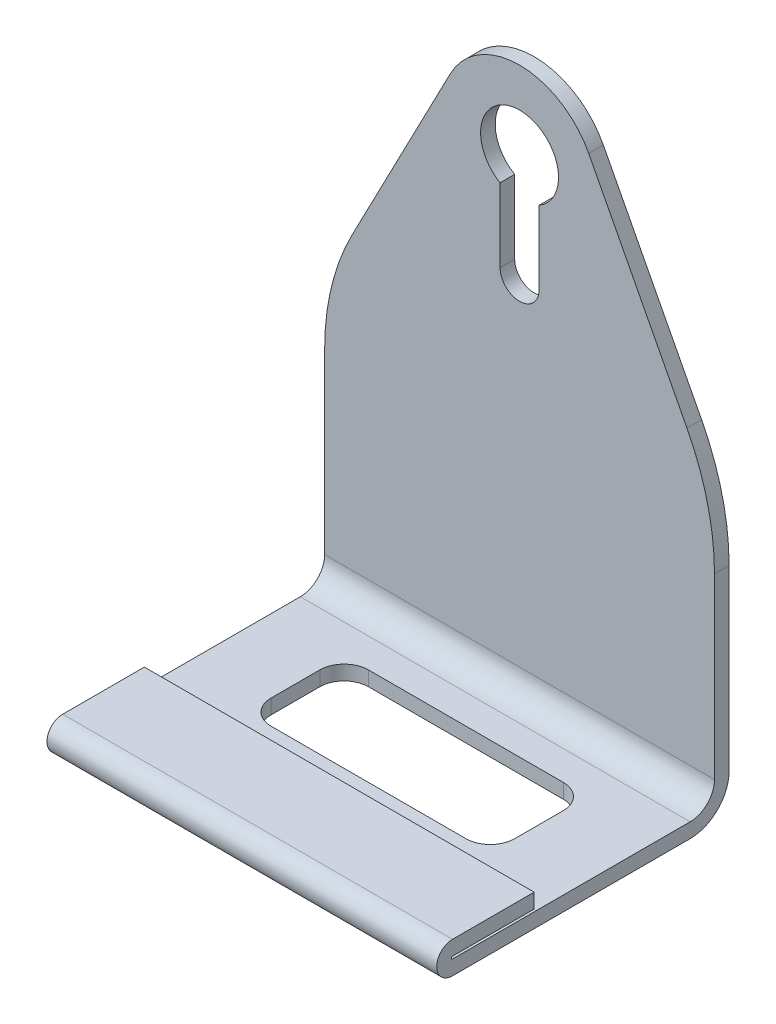
from build123d import *

# Parameters (mm, degrees)
BOSS_EXTRUDE1_DEPTH     = 40
CUT_EXTRUDE2_DEPTH      = 58
CUT_EXTRUDE2_DEPTH_BACK = 4
FILLET2_R               = 50
SKETCH4_R               = 8
CUT_EXTRUDE4_DEPTH      = 58
CUT_EXTRUDE4_DEPTH_BACK = 4
CUT_EXTRUDE5_DEPTH      = 113
CUT_EXTRUDE5_DEPTH_BACK = 4


with BuildPart() as part:
    # Sketch1 → Boss-Extrude1 (new body, symmetric)
    with BuildSketch(Plane.YZ):
        with BuildLine():
            Line((8, 0), (115, 0))
            Line((115, 0), (115, 3))
            Line((115, 3), (8, 3))
            ThreePointArc((8, 3), (4.464466094, 4.464466094), (3, 8))
            Line((3, 8), (3, 56.75))
            ThreePointArc((3, 56.75), (3.25, 57), (3.5, 56.75))
            Line((3.5, 56.75), (3.5, 40))
            Line((3.5, 40), (6.5, 40))
            Line((6.5, 40), (6.5, 56.75))
            ThreePointArc((6.5, 56.75), (3.25, 60), (0, 56.75))
            Line((0, 56.75), (0, 8))
            ThreePointArc((0, 8), (2.343145751, 2.343145751), (8, 0))
        make_face()
    extrude(amount=BOSS_EXTRUDE1_DEPTH, both=True)

    # Sketch2 → Cut-Extrude2 (cut, two sides)
    with BuildSketch(Plane.XY.offset(3)) as cut_extrude2_sk:
        with BuildLine():
            Line((-135.973206715, -127.551210724), (-40, 56.811604044))
            Line((-40, 56.811604044), (-14.192173331, 106.387977812))
            ThreePointArc((-14.192173331, 106.387977812), (0, 115), (14.192173331, 106.387977812))
            Line((14.192173331, 106.387977812), (40, 56.811604044))
            Line((40, 56.811604044), (135.973206715, -127.551210724))
            Line((135.973206715, -127.551210724), (135.973206715, 288.143407362))
            Line((135.973206715, 288.143407362), (-135.973206715, 288.143407362))
            Line((-135.973206715, 288.143407362), (-135.973206715, -127.551210724))
        make_face()
    extrude(amount=CUT_EXTRUDE2_DEPTH, mode=Mode.SUBTRACT)
    extrude(cut_extrude2_sk.sketch, amount=-CUT_EXTRUDE2_DEPTH_BACK, mode=Mode.SUBTRACT)

    # Fillet2
    fillet2_edges = [part.edges().sort_by_distance(p)[0] for p in [
        (-40, 56.811604044, 1.5),
        (40, 56.811604044, 1.5),
    ]]
    fillet(fillet2_edges, radius=FILLET2_R)

    # Sketch4 → Cut-Extrude4 (cut, two sides)
    with BuildSketch(Plane.XY.offset(3)) as cut_extrude4_sk:
        with Locations((0, 99)):
            Circle(SKETCH4_R)
        with BuildLine():
            Line((4, 99), (4, 77))
            ThreePointArc((4, 77), (0, 73), (-4, 77))
            Line((-4, 77), (-4, 99))
            ThreePointArc((-4, 99), (0, 103), (4, 99))
        make_face()
    extrude(amount=CUT_EXTRUDE4_DEPTH, mode=Mode.SUBTRACT)
    extrude(cut_extrude4_sk.sketch, amount=-CUT_EXTRUDE4_DEPTH_BACK, mode=Mode.SUBTRACT)

    # Sketch5 → Cut-Extrude5 (cut, two sides)
    with BuildSketch(Plane(origin=(0, 3, 0), x_dir=(-1, 0, 0), z_dir=(0, 1, 0))) as cut_extrude5_sk:
        with BuildLine():
            Line((-20, 14), (20, 14))
            ThreePointArc((20, 14), (23.535533906, 15.464466094), (25, 19))
            Line((25, 19), (25, 29))
            ThreePointArc((25, 29), (23.535533906, 32.535533906), (20, 34))
            Line((20, 34), (-20, 34))
            ThreePointArc((-20, 34), (-23.535533906, 32.535533906), (-25, 29))
            Line((-25, 29), (-25, 19))
            ThreePointArc((-25, 19), (-23.535533906, 15.464466094), (-20, 14))
        make_face()
    extrude(amount=CUT_EXTRUDE5_DEPTH, mode=Mode.SUBTRACT)
    extrude(cut_extrude5_sk.sketch, amount=-CUT_EXTRUDE5_DEPTH_BACK, mode=Mode.SUBTRACT)


solid = part.part
